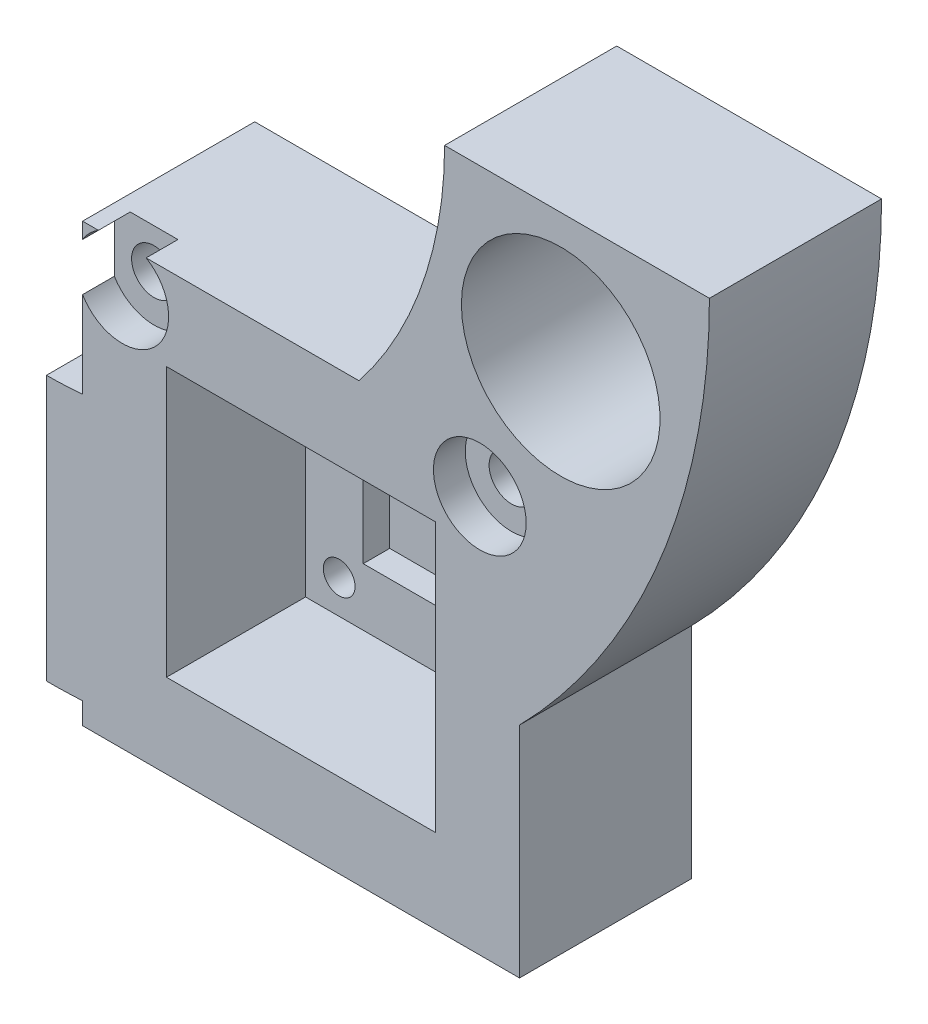
from build123d import *

# Parameters (mm, degrees)
ESQUISSE1_W                                        = 33
ESQUISSE1_H                                        = 33
BOSS_EXTRU_1_DEPTH                                 = 13
ESQUISSE3_R                                        = 2
ESQUISSE3_W                                        = 2.1
ESQUISSE3_H                                        = 2.8
ENL_V_MAT_EXTRU_1_DEPTH                            = 14
ESQUISSE4_W                                        = 11.606208868
ESQUISSE4_H                                        = 11.606208868
ESQUISSE4_R                                        = 2
ENL_V_MAT_EXTRU_2_DEPTH                            = 12.5
ESQUISSE2_R                                        = 1.2
ENL_V_MAT_EXTRU_3_DEPTH                            = 14
ESQUISSE5_W                                        = 20.32
ESQUISSE5_H                                        = 20.32
ENL_V_MAT_EXTRU_5_DEPTH                            = 10.5
ESQUISSE8_R                                        = 7.5
BOSS_EXTRU_4_DEPTH                                 = 13
CHAMBRAGE_POUR_VIS_T_TE_RONDE_BOMB_E_M_D           = 3.4
CHAMBRAGE_POUR_VIS_T_TE_RONDE_BOMB_E_M_CBORE_D     = 7
CHAMBRAGE_POUR_VIS_T_TE_RONDE_BOMB_E_M_CBORE_DEPTH = 2.4


with BuildPart() as part:
    # Esquisse1 → Boss.-Extru.1 (new body)
    with BuildSketch(Plane.XY):
        Rectangle(ESQUISSE1_W, ESQUISSE1_H)
    extrude(amount=BOSS_EXTRU_1_DEPTH)

    # Esquisse3 → Enlèv. mat.-Extru.1 (cut, through all)
    with BuildSketch(Plane.XY.offset(13)):
        with Locations((0.25, 0)):
            Circle(ESQUISSE3_R)
        with Locations((-2.97, 0)):
            Rectangle(ESQUISSE3_W, ESQUISSE3_H)
    extrude(amount=-ENL_V_MAT_EXTRU_1_DEPTH, mode=Mode.SUBTRACT)

    # Esquisse4 → Enlèv. mat.-Extru.2 (cut)
    with BuildSketch(Plane.XY.offset(13)):
        Rectangle(ESQUISSE4_W, ESQUISSE4_H)
        with Locations((0.25, 0)):
            Circle(ESQUISSE4_R, mode=Mode.SUBTRACT)
    extrude(amount=-ENL_V_MAT_EXTRU_2_DEPTH, mode=Mode.SUBTRACT)

    # Esquisse2 → Enlèv. mat.-Extru.3 (cut, through all)
    with BuildSketch(Plane.XY.offset(13)):
        with BuildLine():
            Line((7.62, 8.82), (-7.62, 8.82))
            ThreePointArc((-7.62, 8.82), (-8.82, 7.62), (-7.62, 6.42))
            Line((-7.62, 6.42), (7.62, 6.42))
            ThreePointArc((7.62, 6.42), (8.82, 7.62), (7.62, 8.82))
        make_face()
        with Locations((7.62, -7.62)):
            Circle(ESQUISSE2_R)
        with Locations((-7.62, -7.62)):
            Circle(ESQUISSE2_R)
    extrude(amount=-ENL_V_MAT_EXTRU_3_DEPTH, mode=Mode.SUBTRACT)

    # Esquisse5 → Enlèv. mat.-Extru.5 (cut)
    with BuildSketch(Plane.XY.offset(13)):
        Rectangle(ESQUISSE5_W, ESQUISSE5_H)
    extrude(amount=-ENL_V_MAT_EXTRU_5_DEPTH, mode=Mode.SUBTRACT)

    # Esquisse8 → Boss.-Extru.4 (add)
    with BuildSketch(Plane(origin=(0, 0, 0), x_dir=(-1, 0, 0), z_dir=(0, 0, -1))):
        with BuildLine():
            Line((19.228652316, -14.943489853), (19.228652316, 5.056510147))
            ThreePointArc((19.228652316, 5.056510147), (17.862916767, 5.087541175), (16.5, 5.180570213))
            Line((16.5, 5.180570213), (16.5, -14.869082996))
            ThreePointArc((16.5, -14.869082996), (17.863819007, -14.924884682), (19.228652316, -14.943489853))
        make_face()
        with BuildLine():
            ThreePointArc((-4.37758657, 16.5), (-9.179371873, 25.268372883), (-10.841194523, 35.126356986))
            Line((-10.841194523, 35.126356986), (-30.841194523, 35.126356986))
            ThreePointArc((-30.841194523, 35.126356986), (-27.117424712, 16.178251365), (-16.5, 0.048543968))
            Line((-16.5, 0.048543968), (-16.5, 16.5))
            Line((-16.5, 16.5), (-4.37758657, 16.5))
        make_face()
        with Locations((-19.609840661, 25.370666938)):
            Circle(ESQUISSE8_R, mode=Mode.SUBTRACT)
    extrude(amount=-BOSS_EXTRU_4_DEPTH)

    # Chambrage pour vis à tête ronde bombée M31 (through all)
    with Locations(Plane(origin=(-13.5, 13.5, 13), x_dir=(1, 0, 0), z_dir=(0, 0, 1))):
        with Locations((0, 0), (27, 0)):
            CounterBoreHole(CHAMBRAGE_POUR_VIS_T_TE_RONDE_BOMB_E_M_D / 2, CHAMBRAGE_POUR_VIS_T_TE_RONDE_BOMB_E_M_CBORE_D / 2, CHAMBRAGE_POUR_VIS_T_TE_RONDE_BOMB_E_M_CBORE_DEPTH)


solid = part.part
